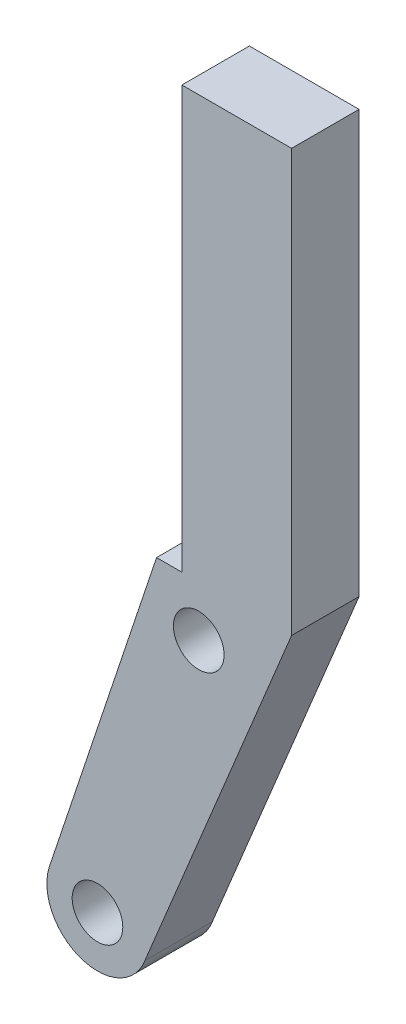
from build123d import *

# Parameters (mm, degrees)
SKETCH1_R           = 1.5
BOSS_EXTRUDE1_DEPTH = 4


with BuildPart() as part:
    # Sketch1 → Boss-Extrude1 (new body)
    with BuildSketch(Plane.XY):
        with BuildLine():
            Line((14.488514014, 22.965384222), (14.488514014, 47.965384222))
            Line((14.488514014, 47.965384222), (7.988514014, 47.965384222))
            Line((7.988514014, 47.965384222), (7.988514014, 22.965384222))
            Line((7.988514014, 22.965384222), (6.488514014, 22.965384222))
            Line((6.488514014, 22.965384222), (0.12000074, 3.87380986))
            ThreePointArc((0.12000074, 3.87380986), (2.018608705, 0.156496466), (5.794859705, 1.93499568))
            Line((5.794859705, 1.93499568), (14.488514014, 22.965384222))
        make_face()
        with Locations((2.988514014, 2.995384222)):
            Circle(SKETCH1_R, mode=Mode.SUBTRACT)
        with Locations((8.988514014, 19.965384222)):
            Circle(SKETCH1_R, mode=Mode.SUBTRACT)
    extrude(amount=BOSS_EXTRUDE1_DEPTH)


solid = part.part
